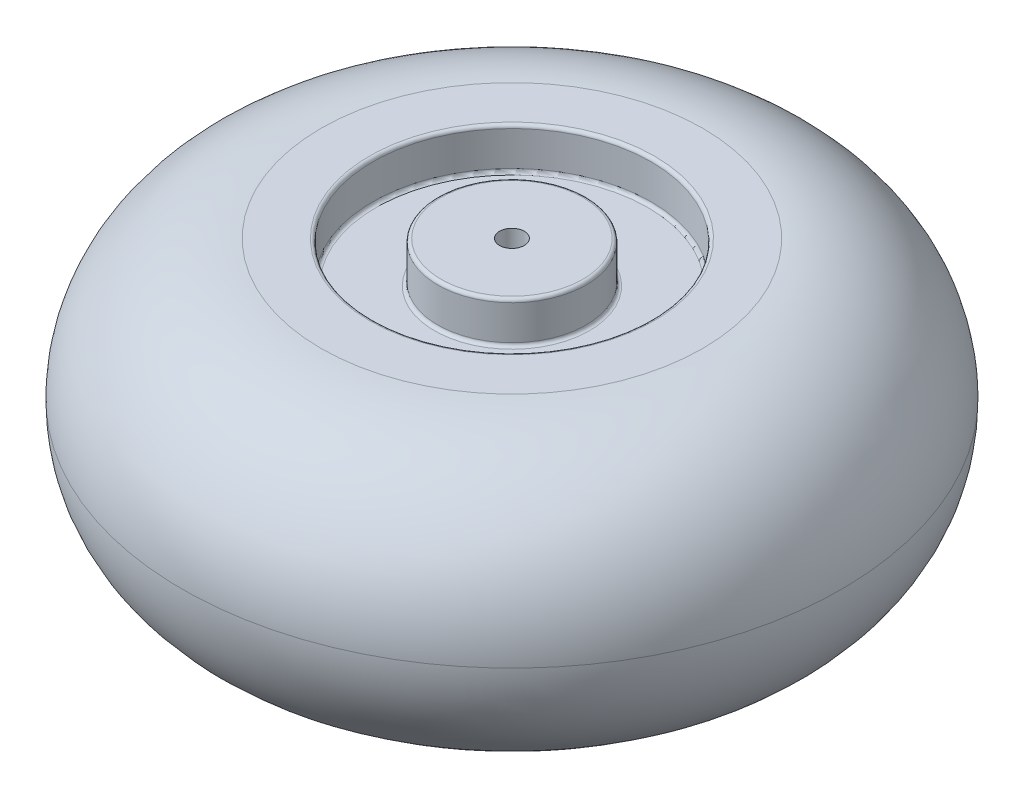
from build123d import *


with BuildPart() as part:
    # Sketch3 → Revolve1 (revolve)
    with BuildSketch(Plane(origin=(0, 0, 0), x_dir=(0, 0, -1), z_dir=(1, 0, 0))):
        with BuildLine():
            Line((6, -67.5), (6, 67.5))
            Line((6, 67.5), (34.386425262, 67.5))
            ThreePointArc((34.386425262, 67.5), (35.527394901, 67.027394901), (36, 65.886425262))
            Line((36, 65.886425262), (36, 49.113574738))
            ThreePointArc((36, 49.113574738), (36.472605099, 47.972605099), (37.613574738, 47.5))
            Line((37.613574738, 47.5), (65.919622929, 47.5))
            ThreePointArc((65.919622929, 47.5), (67.060592569, 47.972605099), (67.533197668, 49.113574738))
            Line((67.533197668, 49.113574738), (67.533197668, 65.886425262))
            ThreePointArc((67.533197668, 65.886425262), (68.005802767, 67.027394901), (69.146772406, 67.5))
            Line((69.146772406, 67.5), (92.533197668, 67.5))
            ThreePointArc((92.533197668, 67.5), (140.200765467, 47.719012588), (159.857324693, 0))
            ThreePointArc((159.857324693, 0), (140.200765467, -47.719012588), (92.533197668, -67.5))
            Line((92.533197668, -67.5), (69.146772406, -67.5))
            ThreePointArc((69.146772406, -67.5), (68.005802767, -67.027394901), (67.533197668, -65.886425262))
            Line((67.533197668, -65.886425262), (67.533197668, -49.113574738))
            ThreePointArc((67.533197668, -49.113574738), (67.060592569, -47.972605099), (65.919622929, -47.5))
            Line((65.919622929, -47.5), (37.613574738, -47.5))
            ThreePointArc((37.613574738, -47.5), (36.472605099, -47.972605099), (36, -49.113574738))
            Line((36, -49.113574738), (36, -65.886425262))
            ThreePointArc((36, -65.886425262), (35.527394901, -67.027394901), (34.386425262, -67.5))
            Line((34.386425262, -67.5), (6, -67.5))
        make_face()
    revolve(axis=Axis((0, 0, 0), (0, 1, 0)))


solid = part.part
